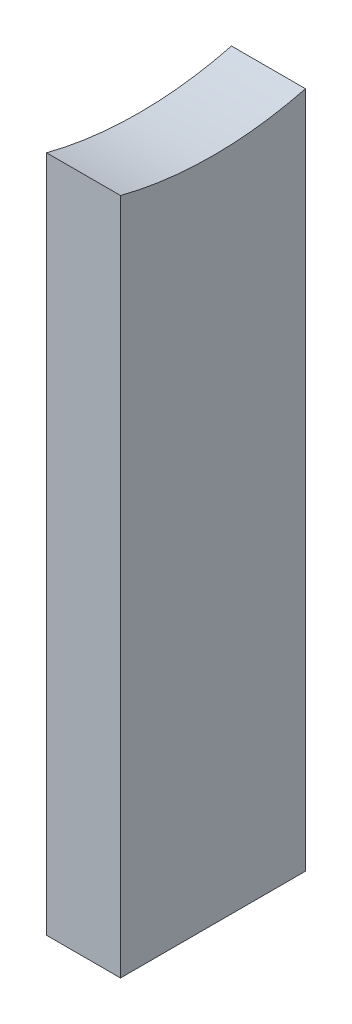
from build123d import *

# Parameters (mm, degrees)
BOSS_EXTRUDE1_DEPTH = 5.08


with BuildPart() as part:
    # Sketch1 → Boss-Extrude1 (new body)
    with BuildSketch(Plane(origin=(0, 0, 0), x_dir=(0, 0, -1), z_dir=(1, 0, 0))):
        with BuildLine():
            Line((-6.35, -24.593444248), (-6.35, -71.12))
            Line((-6.35, -71.12), (6.35, -71.12))
            Line((6.35, -71.12), (6.35, -24.593444248))
            ThreePointArc((6.35, -24.593444248), (0, -25.4), (-6.35, -24.593444248))
        make_face()
    extrude(amount=BOSS_EXTRUDE1_DEPTH)


solid = part.part
